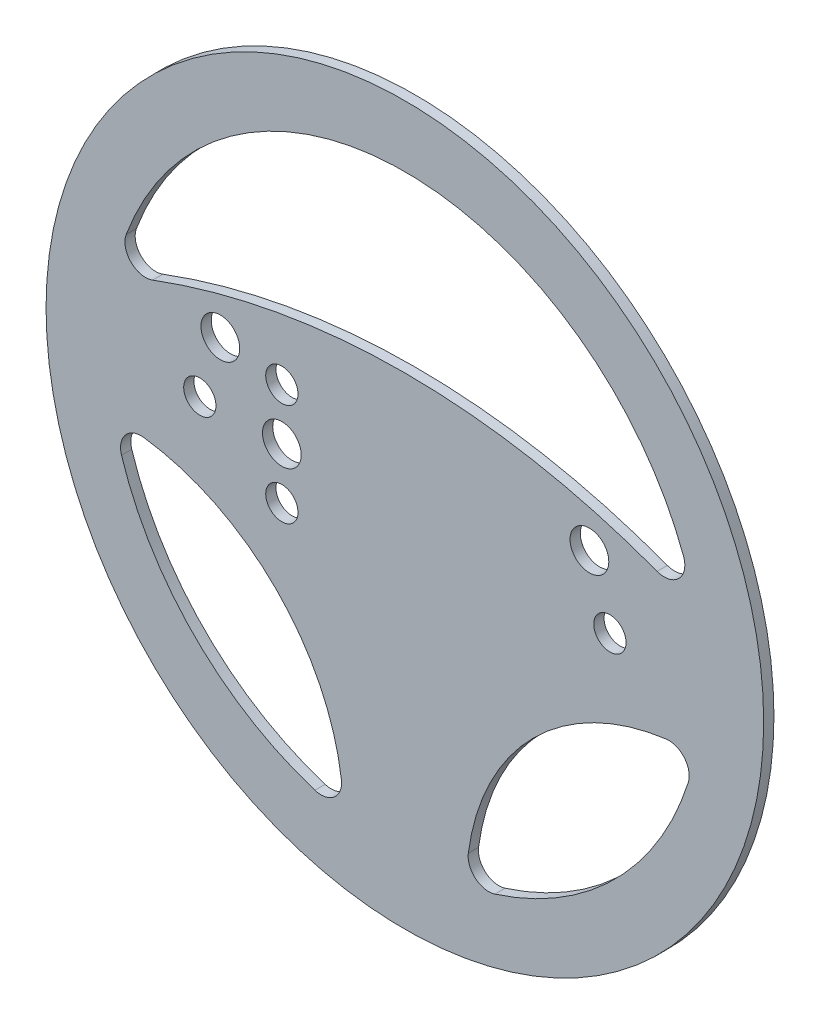
from build123d import *

# Parameters (mm, degrees)
SKETCH1_R           = 111.125
BOSS_EXTRUDE1_DEPTH = 3.175
SKETCH2_R           = 5.999999938
SKETCH2_R_2         = 5.000000033
CUT_EXTRUDE1_DEPTH  = 3.175


with BuildPart() as part:
    # Sketch1 → Boss-Extrude1 (new body)
    with BuildSketch(Plane.XY):
        Circle(SKETCH1_R)
        with BuildLine():
            ThreePointArc((-78.118809332, 23.936541993), (0, 38.1), (78.118809332, 23.936541993))
            ThreePointArc((78.118809332, 23.936541993), (84.832280885, 25.386264259), (86.299834064, 32.095860566))
            ThreePointArc((86.299834064, 32.095860566), (0, 92.075), (-86.299834064, 32.095860566))
            ThreePointArc((-86.299834064, 32.095860566), (-84.832280885, 25.386264259), (-78.118809332, 23.936541993))
        make_face(mode=Mode.SUBTRACT)
        with BuildLine():
            ThreePointArc((19.648389698, -80.882079401), (39.855012865, -39.855012865), (80.882079401, -19.648389698))
            ThreePointArc((80.882079401, -19.648389698), (86.575177486, -21.870616714), (87.75676836, -27.866740606))
            ThreePointArc((87.75676836, -27.866740606), (65.106856878, -65.106856878), (27.866740606, -87.75676836))
            ThreePointArc((27.866740606, -87.75676836), (21.870616714, -86.575177486), (19.648389698, -80.882079401))
        make_face(mode=Mode.SUBTRACT)
        with BuildLine():
            ThreePointArc((-19.648389698, -80.882079401), (-39.855012865, -39.855012865), (-80.882079401, -19.648389698))
            ThreePointArc((-80.882079401, -19.648389698), (-86.575177486, -21.870616714), (-87.75676836, -27.866740606))
            ThreePointArc((-87.75676836, -27.866740606), (-65.106856878, -65.106856878), (-27.866740606, -87.75676836))
            ThreePointArc((-27.866740606, -87.75676836), (-21.870616714, -86.575177486), (-19.648389698, -80.882079401))
        make_face(mode=Mode.SUBTRACT)
    extrude(amount=BOSS_EXTRUDE1_DEPTH)

    # Sketch2 → Cut-Extrude1 (cut)
    with BuildSketch(Plane(origin=(0, 0, 0), x_dir=(-1, 0, 0), z_dir=(0, 0, -1))):
        with Locations((-57.15, 19.05)):
            Circle(SKETCH2_R)
        with Locations((-63.5, 0)):
            Circle(SKETCH2_R_2)
        with Locations((57.15, 19.05)):
            Circle(SKETCH2_R)
        with Locations((63.5, 0)):
            Circle(SKETCH2_R_2)
        with Locations((38.1, 0)):
            Circle(SKETCH2_R)
        with Locations((38.1, 15.875)):
            Circle(SKETCH2_R_2)
        with Locations((38.1, -15.875)):
            Circle(SKETCH2_R_2)
    extrude(amount=-CUT_EXTRUDE1_DEPTH, mode=Mode.SUBTRACT)


solid = part.part
